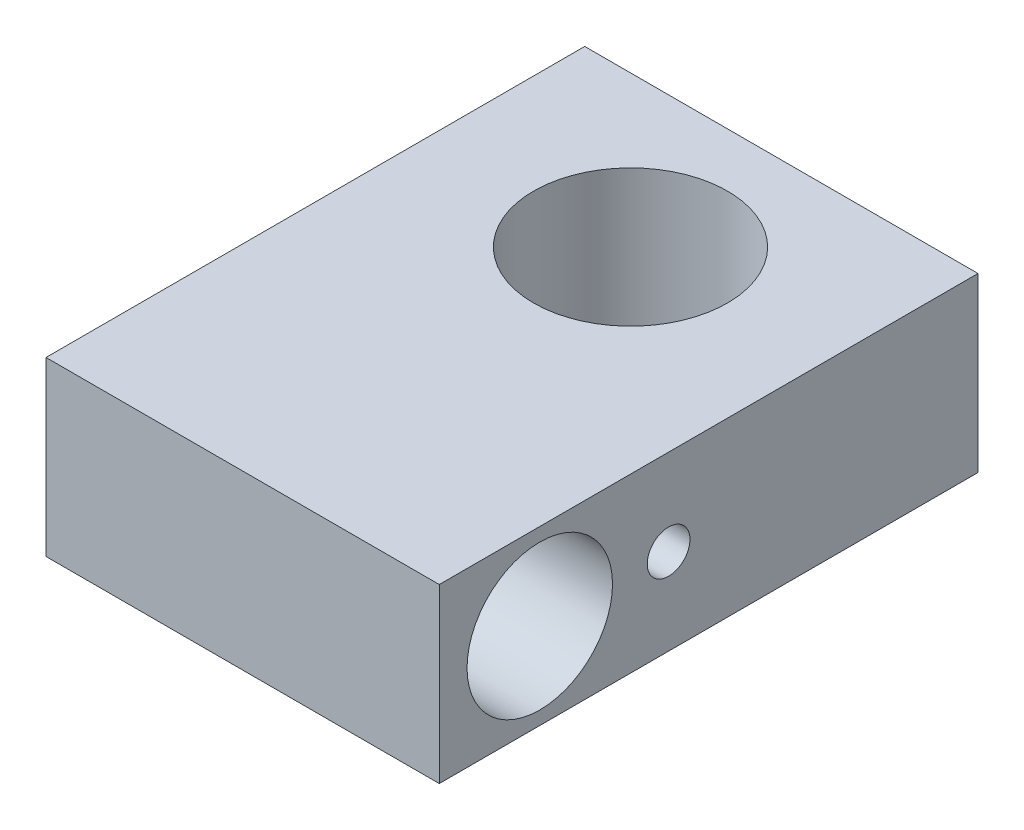
from build123d import *

# Parameters (mm, degrees)
SKETCH1_W              = 18.25
SKETCH1_H              = 25
BOSS_EXTRUDE1_DEPTH    = 8
M10X1_0_TAPPED_HOLE1_D = 9
SKETCH7_R              = 3.375
SKETCH7_R_2            = 0.9906
CUT_EXTRUDE2_DEPTH     = 19.25


with BuildPart() as part:
    # Sketch1 → Boss-Extrude1 (new body)
    with BuildSketch(Plane(origin=(0, 0, 0), x_dir=(1, 0, 0), z_dir=(0, 1, 0))):
        with Locations((0, -5.5)):
            Rectangle(SKETCH1_W, SKETCH1_H)
    extrude(amount=BOSS_EXTRUDE1_DEPTH)

    # M10x1.0 Tapped Hole1 (through all)
    with Locations(Plane(origin=(0, 8, 0), x_dir=(-1, 0, 0), z_dir=(0, 1, 0))):
        with Locations((0, 0)):
            Hole(M10X1_0_TAPPED_HOLE1_D / 2)

    # Sketch7 → Cut-Extrude2 (cut, through all)
    with BuildSketch(Plane(origin=(9.125, 0, 0), x_dir=(0, 0, -1), z_dir=(1, 0, 0))):
        with Locations((-13.336186812, 4)):
            Circle(SKETCH7_R)
        with Locations((-7.3575, 4)):
            Circle(SKETCH7_R_2)
    extrude(amount=-CUT_EXTRUDE2_DEPTH, mode=Mode.SUBTRACT)


solid = part.part
